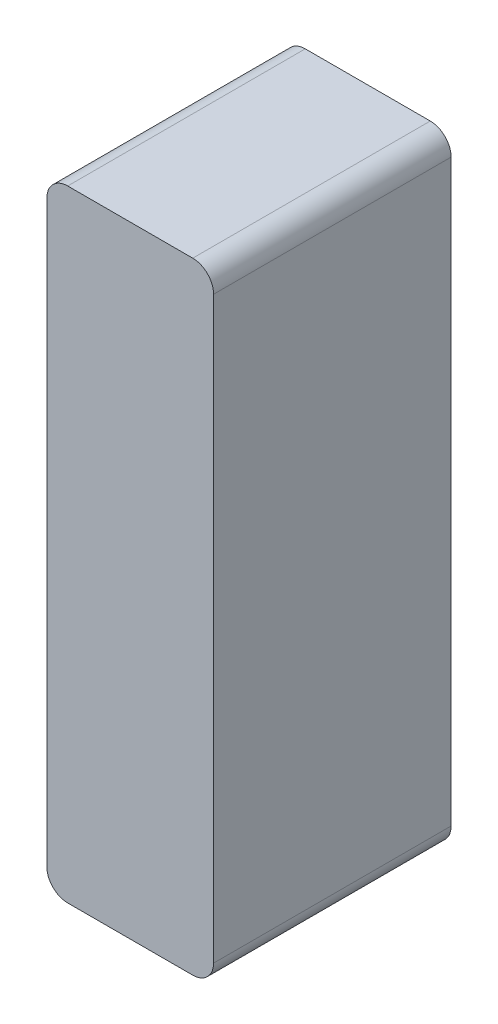
from build123d import *

# Parameters (mm, degrees)
CROQUIS1_W              = 8
CROQUIS1_H              = 29.8
SALIENTE_EXTRUIR1_DEPTH = 11.4
REDONDEO2_R             = 1


with BuildPart() as part:
    # Croquis1 → Saliente-Extruir1 (new body)
    with BuildSketch(Plane.XY):
        Rectangle(CROQUIS1_W, CROQUIS1_H)
    extrude(amount=SALIENTE_EXTRUIR1_DEPTH)

    # Redondeo2
    redondeo2_edges = [part.edges().sort_by_distance(p)[0] for p in [
        (4, -14.9, 5.7),
        (-4, -14.9, 5.7),
        (-4, 14.9, 5.7),
        (4, 14.9, 5.7),
    ]]
    fillet(redondeo2_edges, radius=REDONDEO2_R)


solid = part.part
